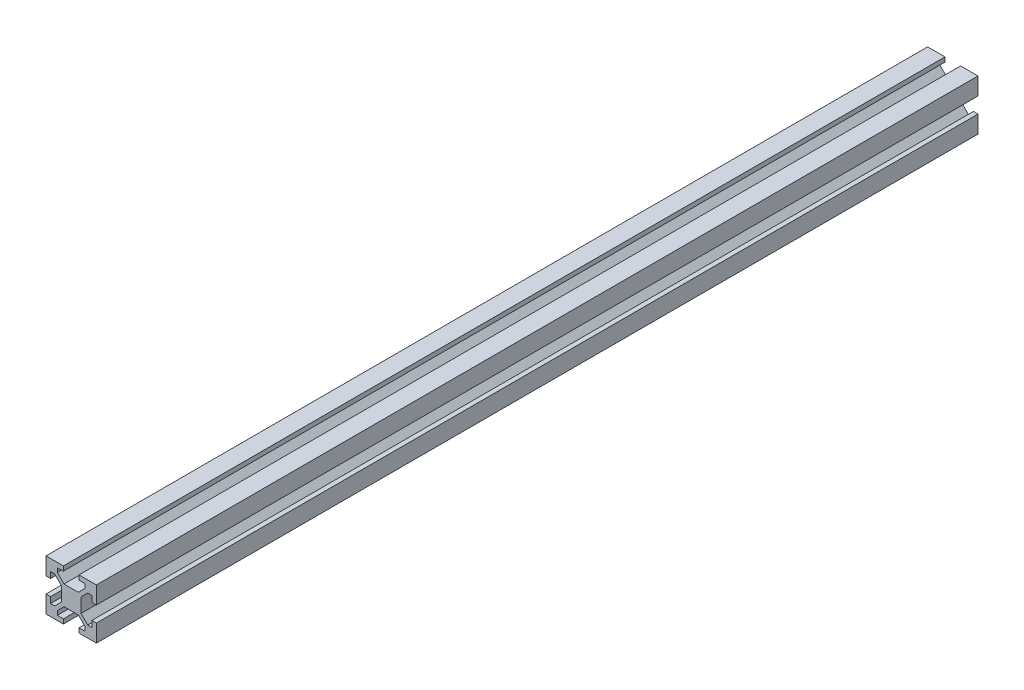
from build123d import *

# Parameters (mm, degrees)
BOSS_EXTRUDE1_DEPTH = 175


with BuildPart() as part:
    # Sketch1 → Boss-Extrude1 (new body, symmetric)
    with BuildSketch(Plane.XY):
        Polygon((-3.1, 10), (-3.1, 8.200660172), (-5.5, 8.200660172), (-5.5, 6.560660172), (-2.84, 3.900660172), (2.84, 3.900660172), (5.5, 6.560660172), (5.5, 8.200660172), (3.1, 8.200660172), (3.1, 10), (10, 10), (10, 3.1), (8.200660172, 3.1), (8.200660172, 5.5), (6.560660172, 5.5), (3.900660172, 2.84), (3.900660172, -2.84), (6.560660172, -5.5), (8.200660172, -5.5), (8.200660172, -3.1), (10, -3.1), (10, -10), (3.1, -10), (3.1, -8.200660172), (5.5, -8.200660172), (5.5, -6.560660172), (2.84, -3.900660172), (-2.84, -3.900660172), (-5.5, -6.560660172), (-5.5, -8.200660172), (-3.1, -8.200660172), (-3.1, -10), (-10, -10), (-10, -3.1), (-8.200660172, -3.1), (-8.200660172, -5.5), (-6.560660172, -5.5), (-3.900660172, -2.84), (-3.900660172, 2.84), (-6.560660172, 5.5), (-8.200660172, 5.5), (-8.200660172, 3.1), (-10, 3.1), (-10, 10), align=None)
    extrude(amount=BOSS_EXTRUDE1_DEPTH, both=True)


solid = part.part
